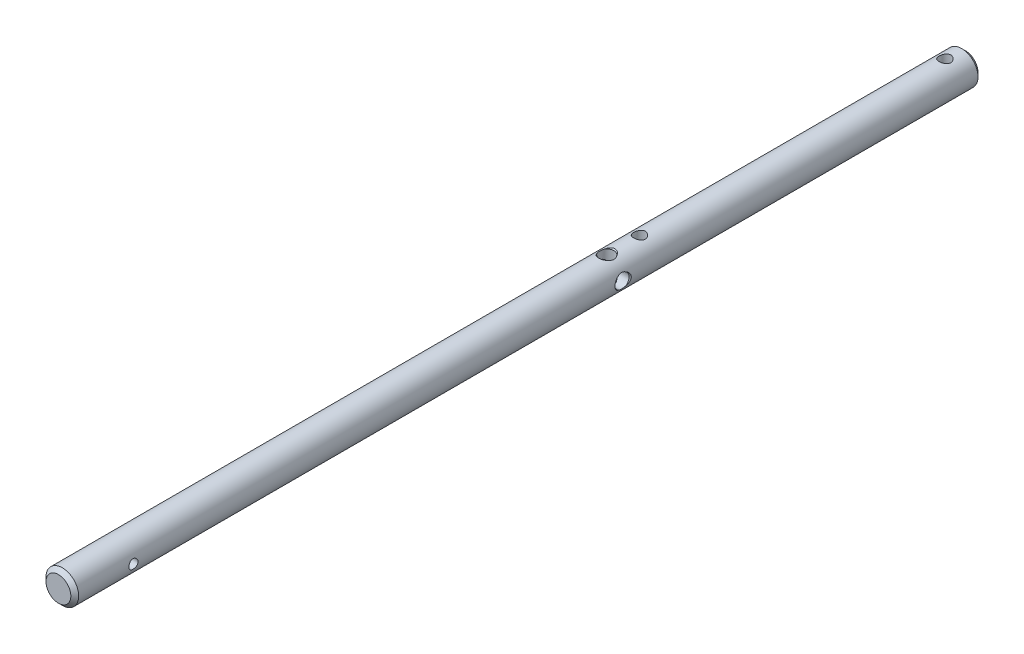
from build123d import *

# Parameters (mm, degrees)
SKETCH1_W                                 = 3.175
SKETCH1_H                                 = 133.223
F_2_56_TAPPED_HOLE1_D                     = 1.778
SKETCH4_R                                 = 3.175
BOSS_EXTRUDE1_DEPTH                       = 43.053
CHAMFER1_SIZE                             = 0.762
F_4_40_TAPPED_HOLE2_D                     = 2.2606
F_7_64_0_10938_DIAMETER_HOLE2_D           = 2.778252
F_7_64_0_10938_DIAMETER_HOLE2_CSINK_D     = 3.175
F_7_64_0_10938_DIAMETER_HOLE2_CSINK_ANGLE = 82


with BuildPart() as part:
    # Sketch1 → Revolve1 (revolve)
    with BuildSketch(Plane.XZ):
        with Locations((1.5875, 66.6115)):
            Rectangle(SKETCH1_W, SKETCH1_H)
    revolve(axis=Axis((0, 0, 133.223), (0, 0, -1)))

    # #2-56 Tapped Hole1 (through all)
    with Locations(Plane(origin=(3.175, 0, 0), x_dir=(0, 0, -1), z_dir=(1, 0, 0))):
        with Locations((-121.801801862, 0)):
            Hole(F_2_56_TAPPED_HOLE1_D / 2)

    # Sketch4 → Boss-Extrude1 (add)
    with BuildSketch(Plane(origin=(0, 0, 0), x_dir=(-1, 0, 0), z_dir=(0, 0, -1))):
        Circle(SKETCH4_R)
    extrude(amount=BOSS_EXTRUDE1_DEPTH)

    # Chamfer1
    chamfer1_edges = [part.edges().sort_by_distance(p)[0] for p in [
        (3.175, 0, -43.053),
        (-3.175, 0, 133.223),
    ]]
    chamfer(chamfer1_edges, length=CHAMFER1_SIZE)

    # #4-40 Tapped Hole2 (through all)
    with Locations(Plane(origin=(0, -3.175, 0), x_dir=(-1, 0, 0), z_dir=(0, -1, 0))):
        with Locations((0, -20.32), (0, 39.0271)):
            Hole(F_4_40_TAPPED_HOLE2_D / 2)

    # Sketch10 → 7/64 (0.10938) Diameter Hole1 (revolve, cut)
    with BuildSketch(Plane(origin=(0, -3.175, 26.67), x_dir=(0, 0, -1), z_dir=(1, 0, 0))):
        Polygon((0, 0), (0, 6.35), (1.5875, 6.35), (1.389126, 6.121796818), (1.389126, 0), align=None)
    revolve(axis=Axis((0, -9.525, 26.67), (0, 1, 0)), mode=Mode.SUBTRACT)

    # 7/64 (0.10938) Diameter Hole2 (through all)
    with Locations(Plane(origin=(3.175, 0, 0), x_dir=(0, 0, -1), z_dir=(1, 0, 0))):
        with Locations((-26.67, 0)):
            CounterSinkHole(F_7_64_0_10938_DIAMETER_HOLE2_D / 2, F_7_64_0_10938_DIAMETER_HOLE2_CSINK_D / 2, counter_sink_angle=F_7_64_0_10938_DIAMETER_HOLE2_CSINK_ANGLE)


solid = part.part
